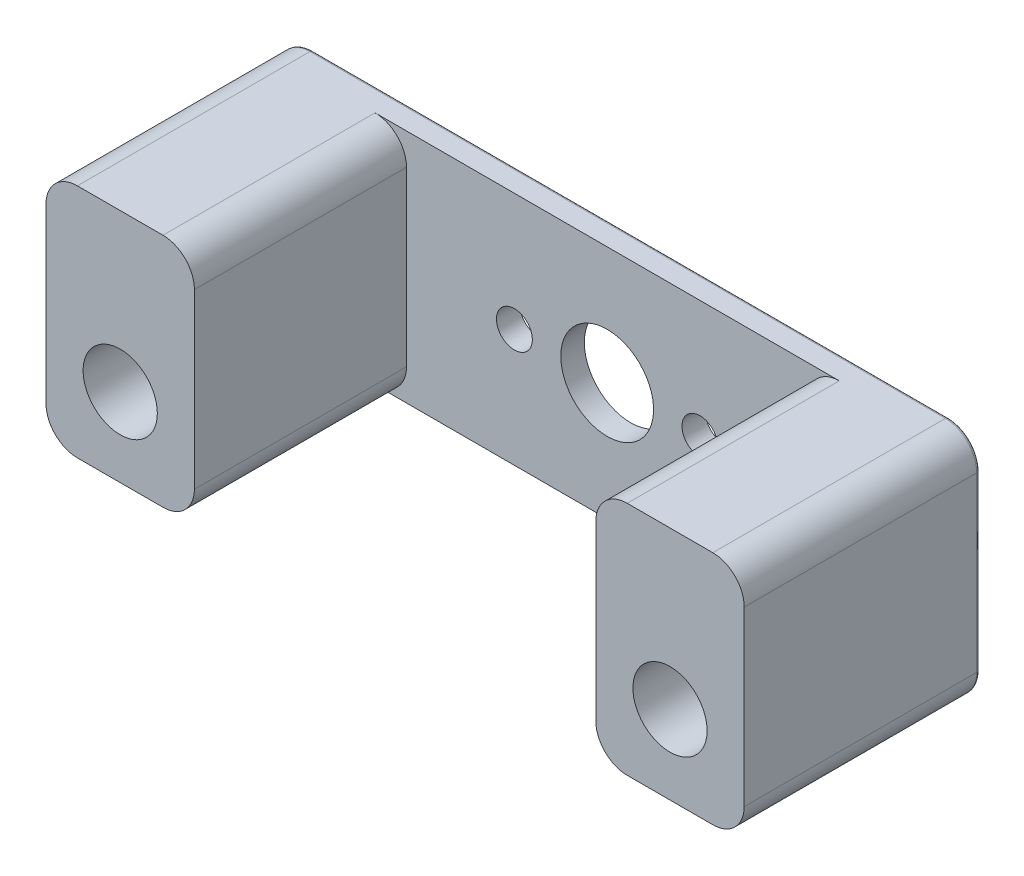
from build123d import *

# Parameters (mm, degrees)
SKETCH1_W           = 56.44896
SKETCH1_H           = 19.05
SKETCH1_R           = 2.99974
BOSS_EXTRUDE1_DEPTH = 19.05
SKETCH2_R           = 1.45
SKETCH2_R_2         = 3.75
CUT_EXTRUDE1_DEPTH  = 19.05
SKETCH3_W           = 32.45104
SKETCH3_H           = 17.145
CUT_EXTRUDE2_DEPTH  = 19.05
FILLET1_R           = 2.54
FILLET3_R           = 0.254


with BuildPart() as part:
    # Sketch1 → Boss-Extrude1 (new body)
    with BuildSketch(Plane.XY):
        Rectangle(SKETCH1_W, SKETCH1_H)
        with Locations((-22.225, -3.175)):
            Circle(SKETCH1_R, mode=Mode.SUBTRACT)
        with Locations((22.225, -3.175)):
            Circle(SKETCH1_R, mode=Mode.SUBTRACT)
    extrude(amount=BOSS_EXTRUDE1_DEPTH)

    # Sketch2 → Cut-Extrude1 (cut)
    with BuildSketch(Plane(origin=(0, 0, 0), x_dir=(-1, 0, 0), z_dir=(0, 0, -1))):
        with Locations((-7.5, 0)):
            Circle(SKETCH2_R)
        with Locations((7.5, 0)):
            Circle(SKETCH2_R)
        Circle(SKETCH2_R_2)
    extrude(amount=-CUT_EXTRUDE1_DEPTH, mode=Mode.SUBTRACT)

    # Sketch3 → Cut-Extrude2 (cut)
    with BuildSketch(Plane(origin=(0, 9.525, 0), x_dir=(1, 0, 0), z_dir=(0, 1, 0))):
        with Locations((0, -10.4775)):
            Rectangle(SKETCH3_W, SKETCH3_H)
    extrude(amount=-CUT_EXTRUDE2_DEPTH, mode=Mode.SUBTRACT)

    # Fillet1
    fillet1_edges = [part.edges().sort_by_distance(p)[0] for p in [
        (28.22448, -9.525, 9.525),
        (-28.22448, -9.525, 9.525),
        (-28.22448, 9.525, 9.525),
        (28.22448, 9.525, 9.525),
        (16.22552, -9.525, 10.4775),
        (16.22552, 9.525, 10.4775),
        (-16.22552, 9.525, 10.4775),
        (-16.22552, -9.525, 10.4775),
    ]]
    fillet(fillet1_edges, radius=FILLET1_R)

    # Fillet3
    fillet3_edges = [part.edges().sort_by_distance(p)[0] for p in [
        (0, -9.525, 0),
        (28.22448, 0, 0),
        (-28.22448, 0, 0),
        (0, 9.525, 0),
        (-27.480531224, 8.781051224, 0),
        (27.480531224, 8.781051224, 0),
        (27.480531224, -8.781051224, 0),
        (-27.480531224, -8.781051224, 0),
    ]]
    fillet(fillet3_edges, radius=FILLET3_R)


solid = part.part
